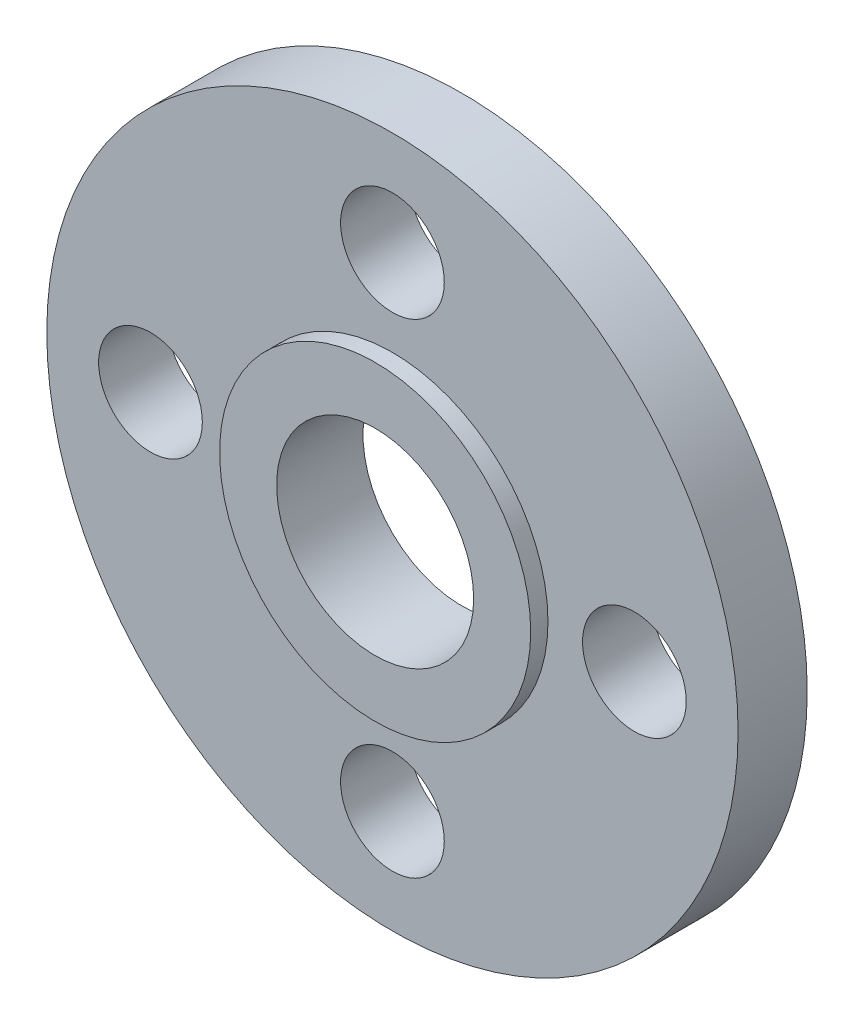
from build123d import *

# Parameters (mm, degrees)
ESQUISSE1_R             = 10
ESQUISSE1_R_2           = 2.85
BOSS_EXTRU_1_DEPTH      = 2
ESQUISSE2_R             = 4.5
ESQUISSE2_R_2           = 2.85
BOSS_EXTRU_2_DEPTH      = 0.5
ESQUISSE3_R             = 1.5
ENL_V_MAT_EXTRU_1_DEPTH = 3


with BuildPart() as part:
    # Esquisse1 → Boss.-Extru.1 (new body)
    with BuildSketch(Plane.XY):
        Circle(ESQUISSE1_R)
        Circle(ESQUISSE1_R_2, mode=Mode.SUBTRACT)
    extrude(amount=BOSS_EXTRU_1_DEPTH)

    # Esquisse2 → Boss.-Extru.2 (add)
    with BuildSketch(Plane.XY.offset(2)):
        Circle(ESQUISSE2_R)
        Circle(ESQUISSE2_R_2, mode=Mode.SUBTRACT)
    extrude(amount=BOSS_EXTRU_2_DEPTH)

    # Esquisse3 → Enlèv. mat.-Extru.1 (cut, through all)
    with BuildSketch(Plane.XY.offset(2)):
        with Locations((0, 7)):
            Circle(ESQUISSE3_R)
        with Locations((0, -7)):
            Circle(ESQUISSE3_R)
        with Locations((7, 0)):
            Circle(ESQUISSE3_R)
        with Locations((-7, 0)):
            Circle(ESQUISSE3_R)
    extrude(amount=-ENL_V_MAT_EXTRU_1_DEPTH, mode=Mode.SUBTRACT)


solid = part.part
